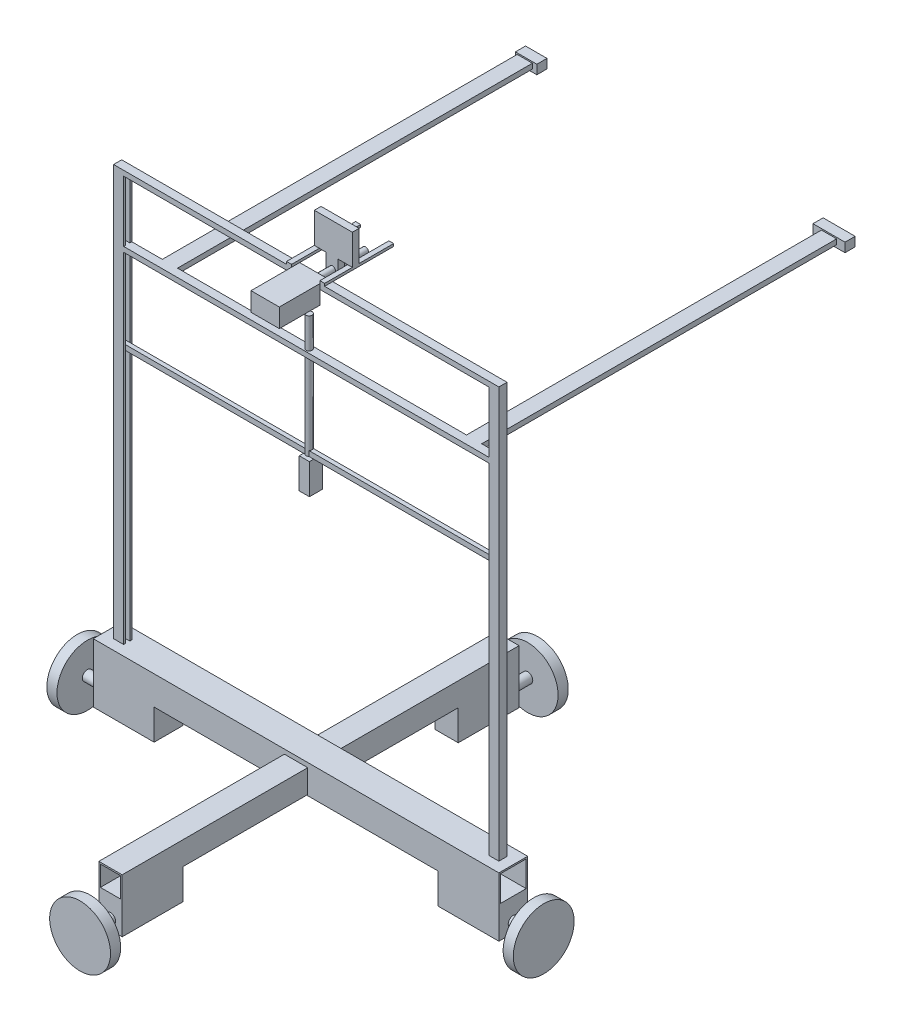
from build123d import *

# Parameters (mm, degrees)
SKETCH1_W                = 28.4
SKETCH1_H                = 28.4
SKETCH1_W_2              = 25.4
SKETCH1_H_2              = 25.4
EXTRUDE_THIN1_DEPTH      = 400
SKETCH2_W                = 23
SKETCH2_H                = 23
SKETCH2_W_2              = 20
SKETCH2_H_2              = 20
EXTRUDE_THIN2_DEPTH      = 183
EXTRUDE_THIN2_DEPTH_BACK = 208.4
SKETCH3_W                = 60
SKETCH3_H                = 28.4
BOSS_EXTRUDE1_DEPTH      = 30
SKETCH4_W                = 23
SKETCH4_H                = 60
BOSS_EXTRUDE2_DEPTH      = 30
SKETCH5_R                = 5
BOSS_EXTRUDE3_DEPTH      = 30
SKETCH6_R                = 5
BOSS_EXTRUDE4_DEPTH      = 30
SKETCH7_R                = 5
BOSS_EXTRUDE5_DEPTH      = 30
SKETCH8_R                = 5
BOSS_EXTRUDE6_DEPTH      = 30
BOSS_EXTRUDE7_DEPTH      = 400
SKETCH10_W               = 372.349277715
SKETCH10_H               = 4
BOSS_EXTRUDE8_DEPTH      = 5
SKETCH11_W               = 380
SKETCH11_H               = 8
BOSS_EXTRUDE9_DEPTH      = 5
SKETCH12_W               = 27.915252313
SKETCH12_H               = 18.485240527
BOSS_EXTRUDE10_DEPTH     = 40
SKETCH13_R               = 3
BOSS_EXTRUDE11_DEPTH     = 60
SKETCH14_W               = 4.655382852
SKETCH14_H               = 68.075309474
SKETCH14_W_2             = 4.976973146
BOSS_EXTRUDE12_DEPTH     = 2.5
SKETCH15_W               = 37.547608311
SKETCH15_H               = 6.653489581
BOSS_EXTRUDE13_DEPTH     = 30
SKETCH16_W               = 11.532338845
SKETCH16_H               = 6.653489581
BOSS_EXTRUDE14_DEPTH     = 16
SKETCH17_W               = 10.054157613
SKETCH17_H               = 12.862513988
BOSS_EXTRUDE15_DEPTH     = 30
SKETCH18_R               = 3
BOSS_EXTRUDE16_DEPTH     = 120
SKETCH19_W               = 380
SKETCH19_H               = 8
BOSS_EXTRUDE17_DEPTH     = 5
SKETCH22_W               = 15
SKETCH22_H               = 5
BOSS_EXTRUDE18_DEPTH     = 350
SKETCH23_W               = 21.129059452
SKETCH23_H               = 9.044463221
SKETCH23_W_2             = 31.579735641
BOSS_EXTRUDE19_DEPTH     = 10
SKETCH24_R               = 30
BOSS_EXTRUDE20_DEPTH     = 10
SKETCH25_R               = 30
BOSS_EXTRUDE21_DEPTH     = 10
SKETCH26_R               = 30
BOSS_EXTRUDE22_DEPTH     = 10
SKETCH27_R               = 30
BOSS_EXTRUDE23_DEPTH     = 10


with BuildPart() as part:
    # Sketch1 → Extrude-Thin1 (new body)
    with BuildSketch(Plane(origin=(0, 0, 0), x_dir=(0, 0, -1), z_dir=(1, 0, 0))):
        Rectangle(SKETCH1_W, SKETCH1_H)
        Rectangle(SKETCH1_W_2, SKETCH1_H_2, mode=Mode.SUBTRACT)
    extrude(amount=EXTRUDE_THIN1_DEPTH)

    # Sketch2 → Extrude-Thin2 (add, two sides)
    with BuildSketch(Plane.XY.offset(14.2)) as extrude_thin2_sk:
        with Locations((200, -1.693644648)):
            Rectangle(SKETCH2_W, SKETCH2_H)
        with Locations((200, -1.693644648)):
            Rectangle(SKETCH2_W_2, SKETCH2_H_2, mode=Mode.SUBTRACT)
    extrude(amount=EXTRUDE_THIN2_DEPTH)
    extrude(extrude_thin2_sk.sketch, amount=-EXTRUDE_THIN2_DEPTH_BACK)

    # Sketch3 → Boss-Extrude1 (add)
    with BuildSketch(Plane(origin=(0, -14.2, 0), x_dir=(-1, 0, 0), z_dir=(0, -1, 0))):
        with Locations((-370, 0)):
            Rectangle(SKETCH3_W, SKETCH3_H)
        with Locations((-30, 0)):
            Rectangle(SKETCH3_W, SKETCH3_H)
    extrude(amount=BOSS_EXTRUDE1_DEPTH)

    # Sketch4 → Boss-Extrude2 (add)
    with BuildSketch(Plane(origin=(0, -13.193644648, 0), x_dir=(-1, 0, 0), z_dir=(0, -1, 0))):
        with Locations((-200, -167.2)):
            Rectangle(SKETCH4_W, SKETCH4_H)
        with Locations((-200, 164.2)):
            Rectangle(SKETCH4_W, SKETCH4_H)
    extrude(amount=BOSS_EXTRUDE2_DEPTH)

    # Sketch5 → Boss-Extrude3 (add)
    with BuildSketch(Plane(origin=(400, 0, 0), x_dir=(0, 0, -1), z_dir=(1, 0, 0))):
        with Locations((0, -34.2)):
            Circle(SKETCH5_R)
    extrude(amount=BOSS_EXTRUDE3_DEPTH)

    # Sketch6 → Boss-Extrude4 (add)
    with BuildSketch(Plane(origin=(0, 0, -194.2), x_dir=(-1, 0, 0), z_dir=(0, 0, -1))):
        with Locations((-200, -33.193644648)):
            Circle(SKETCH6_R)
    extrude(amount=BOSS_EXTRUDE4_DEPTH)

    # Sketch7 → Boss-Extrude5 (add)
    with BuildSketch(Plane.ZY):
        with Locations((0, -34.2)):
            Circle(SKETCH7_R)
    extrude(amount=BOSS_EXTRUDE5_DEPTH)

    # Sketch8 → Boss-Extrude6 (add)
    with BuildSketch(Plane.XY.offset(197.2)):
        with Locations((200, -33.193644648)):
            Circle(SKETCH8_R)
    extrude(amount=BOSS_EXTRUDE6_DEPTH)

    # Sketch9 → Boss-Extrude7 (add)
    with BuildSketch(Plane(origin=(0, 14.2, 0), x_dir=(1, 0, 0), z_dir=(0, 1, 0))):
        Polygon((10, 3.8), (20, 3.8), (20, 1.8), (13.177515759, 1.8), (13.177515759, -2.2), (20, -2.2), (20, -4.2), (10, -4.2), align=None)
        Polygon((380, 3.8), (390, 3.8), (390, -4.2), (380, -4.2), (380, -2.2), (385.526793474, -2.2), (385.526793474, 1.8), (380, 1.8), align=None)
    extrude(amount=BOSS_EXTRUDE7_DEPTH)

    # Sketch10 → Boss-Extrude8 (add)
    with BuildSketch(Plane(origin=(0, 264.2, 0), x_dir=(1, 0, 0), z_dir=(0, 1, 0))):
        with Locations((199.352154617, -0.2)):
            Rectangle(SKETCH10_W, SKETCH10_H)
    extrude(amount=BOSS_EXTRUDE8_DEPTH)

    # Sketch11 → Boss-Extrude9 (add)
    with BuildSketch(Plane(origin=(0, 414.2, 0), x_dir=(1, 0, 0), z_dir=(0, 1, 0))):
        with Locations((200, -0.2)):
            Rectangle(SKETCH11_W, SKETCH11_H)
    extrude(amount=BOSS_EXTRUDE9_DEPTH)

    # Sketch12 → Boss-Extrude10 (add)
    with BuildSketch(Plane.XY.offset(4.2)):
        with Locations((199.518702547, 409.957379737)):
            Rectangle(SKETCH12_W, SKETCH12_H)
    extrude(amount=BOSS_EXTRUDE10_DEPTH)

    # Sketch13 → Boss-Extrude11 (add)
    with BuildSketch(Plane(origin=(0, 0, 4.2), x_dir=(-1, 0, 0), z_dir=(0, 0, -1))):
        with Locations((-198.49073191, 410.167255752)):
            Circle(SKETCH13_R)
    extrude(amount=BOSS_EXTRUDE11_DEPTH)

    # Sketch14 → Boss-Extrude12 (add)
    with BuildSketch(Plane(origin=(0, 419.2, 0), x_dir=(1, 0, 0), z_dir=(0, 1, 0))):
        with Locations((215.804020129, 29.837654737)):
            Rectangle(SKETCH14_W, SKETCH14_H)
        with Locations((183.072589817, 29.837654737)):
            Rectangle(SKETCH14_W_2, SKETCH14_H)
    extrude(amount=BOSS_EXTRUDE12_DEPTH)

    # Sketch15 → Boss-Extrude13 (add)
    with BuildSketch(Plane(origin=(0, 421.7, 0), x_dir=(1, 0, 0), z_dir=(0, 1, 0))):
        with Locations((199.357907399, 26.510909946)):
            Rectangle(SKETCH15_W, SKETCH15_H)
    extrude(amount=BOSS_EXTRUDE13_DEPTH)

    # Sketch16 → Boss-Extrude14 (add)
    with BuildSketch(Plane(origin=(0, 421.7, 0), x_dir=(-1, 0, 0), z_dir=(0, -1, 0))):
        with Locations((-198.059420633, 26.510909946)):
            Rectangle(SKETCH16_W, SKETCH16_H)
    extrude(amount=BOSS_EXTRUDE14_DEPTH)

    # Sketch17 → Boss-Extrude15 (add)
    with BuildSketch(Plane(origin=(0, 264.2, 0), x_dir=(-1, 0, 0), z_dir=(0, -1, 0))):
        with Locations((-200.355829852, 0)):
            Rectangle(SKETCH17_W, SKETCH17_H)
    extrude(amount=BOSS_EXTRUDE15_DEPTH)

    # Sketch18 → Boss-Extrude16 (add)
    with BuildSketch(Plane(origin=(0, 264.2, 0), x_dir=(1, 0, 0), z_dir=(0, 1, 0))):
        with Locations((198.604681124, 0)):
            Circle(SKETCH18_R)
    extrude(amount=BOSS_EXTRUDE16_DEPTH)

    # Sketch19 → Boss-Extrude17 (add)
    with BuildSketch(Plane(origin=(0, 349.2, 0), x_dir=(1, 0, 0), z_dir=(0, 1, 0))):
        with Locations((200, -0.2)):
            Rectangle(SKETCH19_W, SKETCH19_H)
    extrude(amount=BOSS_EXTRUDE17_DEPTH)

    # Sketch22 → Boss-Extrude18 (add)
    with BuildSketch(Plane(origin=(0, 0, -3.8), x_dir=(-1, 0, 0), z_dir=(0, 0, -1))):
        with Locations((-357.561728319, 351.7)):
            Rectangle(SKETCH22_W, SKETCH22_H)
        with Locations((-57.561728319, 351.7)):
            Rectangle(SKETCH22_W, SKETCH22_H)
    extrude(amount=BOSS_EXTRUDE18_DEPTH)

    # Sketch23 → Boss-Extrude19 (add)
    with BuildSketch(Plane(origin=(0, 0, -353.8), x_dir=(-1, 0, 0), z_dir=(0, 0, -1))):
        with Locations((-58.848339235, 350.994945207)):
            Rectangle(SKETCH23_W, SKETCH23_H)
        with Locations((-357.551157011, 350.994945207)):
            Rectangle(SKETCH23_W_2, SKETCH23_H)
    extrude(amount=BOSS_EXTRUDE19_DEPTH)

    # Sketch24 → Boss-Extrude20 (add)
    with BuildSketch(Plane(origin=(0, 0, -224.2), x_dir=(-1, 0, 0), z_dir=(0, 0, -1))):
        with Locations((-200, -33.193644648)):
            Circle(SKETCH24_R)
    extrude(amount=-BOSS_EXTRUDE20_DEPTH)

    # Sketch25 → Boss-Extrude21 (add)
    with BuildSketch(Plane.ZY.offset(30)):
        with Locations((0, -34.2)):
            Circle(SKETCH25_R)
    extrude(amount=-BOSS_EXTRUDE21_DEPTH)

    # Sketch26 → Boss-Extrude22 (add)
    with BuildSketch(Plane.XY.offset(227.2)):
        with Locations((200, -33.193644648)):
            Circle(SKETCH26_R)
    extrude(amount=-BOSS_EXTRUDE22_DEPTH)

    # Sketch27 → Boss-Extrude23 (add)
    with BuildSketch(Plane(origin=(430, 0, 0), x_dir=(0, 0, -1), z_dir=(1, 0, 0))):
        with Locations((0, -34.2)):
            Circle(SKETCH27_R)
    extrude(amount=-BOSS_EXTRUDE23_DEPTH)


solid = part.part
